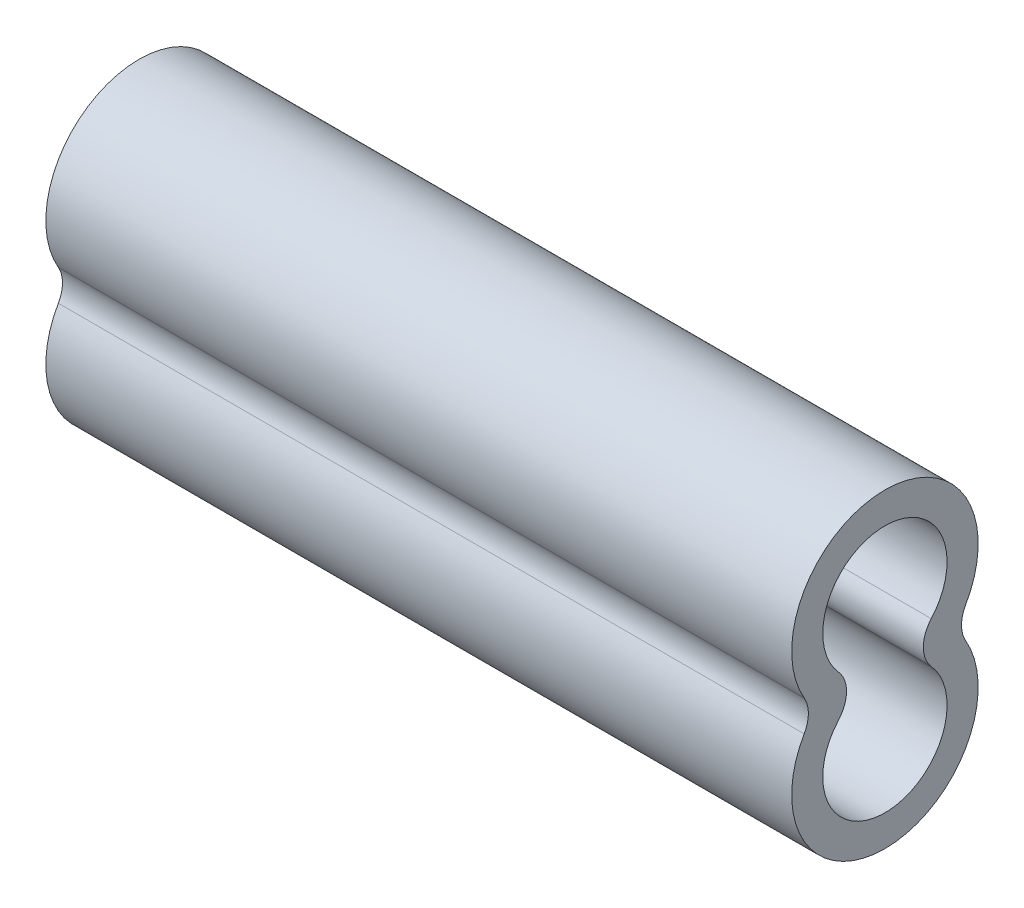
from build123d import *

# Parameters (mm, degrees)
BOSS_EXTRUDE1_DEPTH = 9.525
FILLET1_R           = 0.396875


with BuildPart() as part:
    # Sketch1 → Boss-Extrude1 (new body)
    with BuildSketch(Plane(origin=(0, 0, 0), x_dir=(0, 0, -1), z_dir=(1, 0, 0))):
        with BuildLine():
            ThreePointArc((0.83712048, 0), (-0.050318999, 1.984375), (-0.937758477, 0))
            ThreePointArc((-0.937758477, 0), (-0.050318999, -1.984375), (0.83712048, 0))
        make_face()
        with BuildLine():
            ThreePointArc((0.54130732, 0.264583333), (-0.050318999, 1.5875), (-0.641945318, 0.264583333))
            ThreePointArc((-0.641945318, 0.264583333), (-0.540883477, 0), (-0.641945318, -0.264583333))
            ThreePointArc((-0.641945318, -0.264583333), (-0.050318999, -1.5875), (0.54130732, -0.264583333))
            ThreePointArc((0.54130732, -0.264583333), (0.44024548, 0), (0.54130732, 0.264583333))
        make_face(mode=Mode.SUBTRACT)
    extrude(amount=BOSS_EXTRUDE1_DEPTH)

    # Fillet1
    fillet1_edges = [part.edges().sort_by_distance(p)[0] for p in [
        (4.7625, 0, 0.937758477),
        (4.7625, 0, -0.83712048),
    ]]
    fillet(fillet1_edges, radius=FILLET1_R)


solid = part.part
